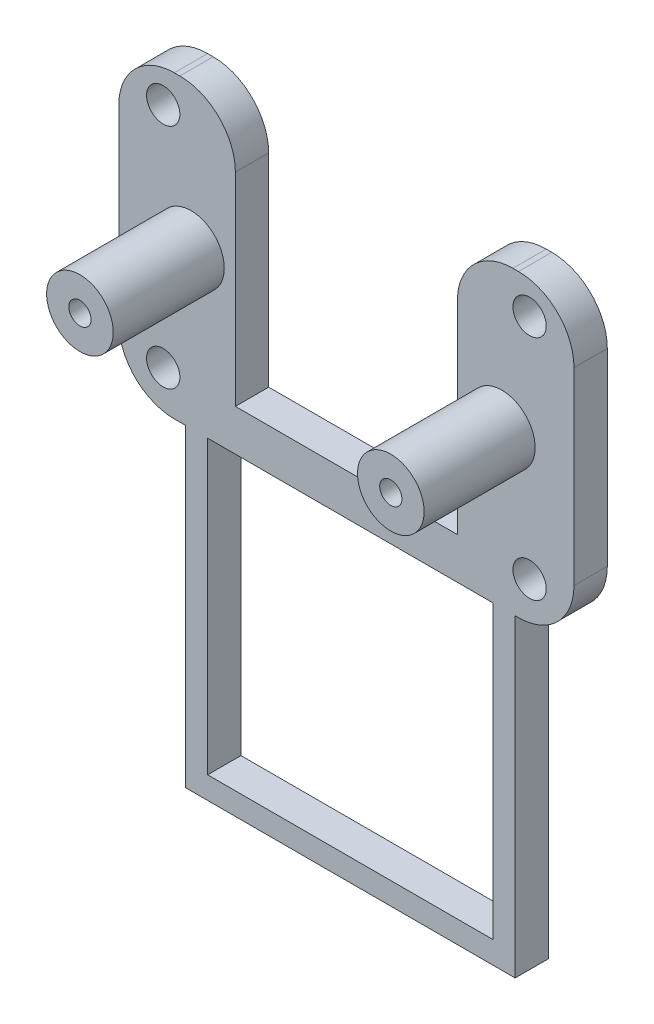
from build123d import *

# Parameters (mm, degrees)
ESQUISSE1_R        = 1.5
BOSS_EXTRU_1_DEPTH = 3
ESQUISSE3_R        = 3
ESQUISSE3_R_2      = 1
BOSS_EXTRU_2_DEPTH = 10
CONG_1_R           = 5
BOSS_EXTRU_3_DEPTH = 3


with BuildPart() as part:
    # Esquisse1 → Boss.-Extru.1 (new body)
    with BuildSketch(Plane.XY):
        Polygon((0, 27), (0, 0), (5.65, 0), (7.65, 0), (7.700374591, 0), (16.027478889, 0), (33.35, 0), (35.35, 0), (41, 0), (41, 27), (30.5, 27), (30.5, 3.727272727), (10.5, 3.727272727), (10.5, 27), align=None)
        with Locations((4, 3.498076118)):
            Circle(ESQUISSE1_R, mode=Mode.SUBTRACT)
        with Locations((36.99999993, 3.500228257)):
            Circle(ESQUISSE1_R, mode=Mode.SUBTRACT)
        with Locations((4, 23.998076118)):
            Circle(ESQUISSE1_R, mode=Mode.SUBTRACT)
        with Locations((36.99999993, 23.998304375)):
            Circle(ESQUISSE1_R, mode=Mode.SUBTRACT)
    extrude(amount=BOSS_EXTRU_1_DEPTH)

    # Esquisse3 → Boss.-Extru.2 (add)
    with BuildSketch(Plane.XY.offset(3)):
        with Locations((6.5, 14)):
            Circle(ESQUISSE3_R)
        with Locations((6.5, 14)):
            Circle(ESQUISSE3_R_2, mode=Mode.SUBTRACT)
        with Locations((34.5, 14)):
            Circle(ESQUISSE3_R)
        with Locations((34.5, 14)):
            Circle(ESQUISSE3_R_2, mode=Mode.SUBTRACT)
    extrude(amount=BOSS_EXTRU_2_DEPTH)

    # Congé1
    cong_1_edges = [part.edges().sort_by_distance(p)[0] for p in [
        (30.5, 27, 1.5),
        (41, 27, 1.5),
        (41, 0, 1.5),
        (0, 0, 1.5),
        (0, 27, 1.5),
        (10.5, 27, 1.5),
    ]]
    fillet(cong_1_edges, radius=CONG_1_R)

    # Esquisse5 → Boss.-Extru.3 (add)
    with BuildSketch(Plane.XY.offset(3)):
        Polygon((8, 0), (6, 0), (6, -28.26), (35.7, -28.26), (35.7, 0), (33.7, 0), (33.7, -26.26), (8, -26.26), align=None)
    extrude(amount=-BOSS_EXTRU_3_DEPTH)


solid = part.part
